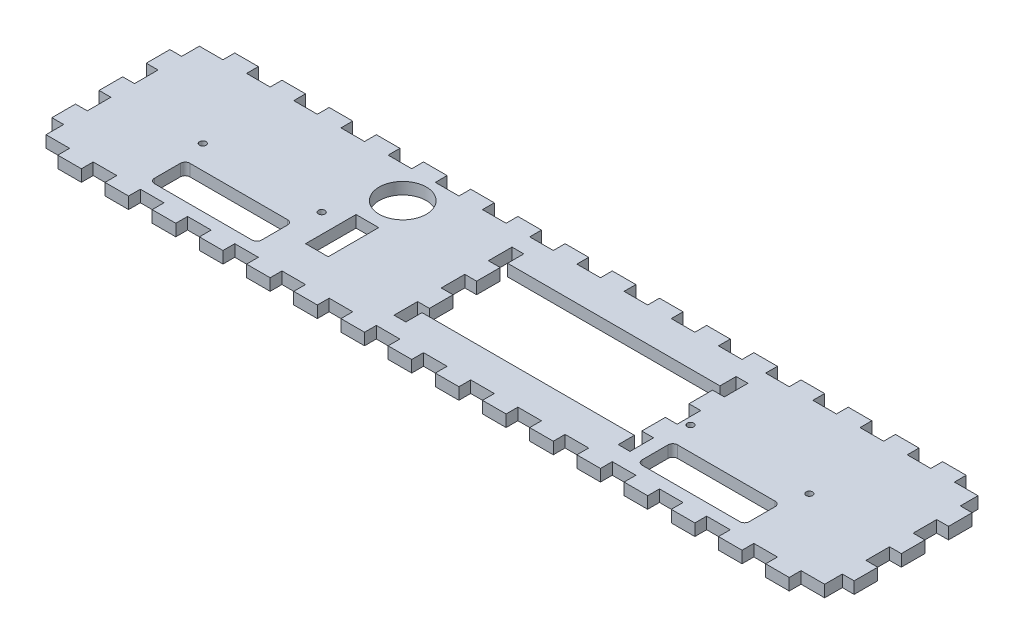
from build123d import *

# Parameters (mm, degrees)
SKETCH1_W           = 431.8
SKETCH1_H           = 95.25
BOSS_EXTRUDE1_DEPTH = 6.35
SKETCH2_W           = 12.7
SKETCH2_H           = 6.35
CUT_EXTRUDE1_DEPTH  = 7.35
LPATTERN1_COUNT     = 17
LPATTERN1_PITCH     = 25.4
SKETCH3_W           = 6.35
SKETCH3_H           = 6.35
CUT_EXTRUDE2_DEPTH  = 7.35
SKETCH5_W           = 6.35
SKETCH5_H           = 12.7
CUT_EXTRUDE4_DEPTH  = 7.35
LPATTERN2_COUNT     = 2
LPATTERN2_PITCH     = 25.4
LPATTERN2_COL_COUNT = 2
LPATTERN2_COL_PITCH = 25.4
SKETCH6_W           = 114.3
SKETCH6_H           = 46.0375
CUT_EXTRUDE5_DEPTH  = 7.35
SKETCH7_R           = 1.75
CUT_EXTRUDE6_DEPTH  = 7.35
SKETCH8_W           = 6.35
SKETCH8_H           = 9.525
SKETCH8_H_2         = 12.7
CUT_EXTRUDE7_DEPTH  = 7.35
LPATTERN3_COUNT     = 2
LPATTERN3_PITCH     = 425.45
SKETCH9_R           = 12.7
SKETCH9_W           = 12.192
SKETCH9_H           = 27.178
CUT_EXTRUDE8_DEPTH  = 7.35
SKETCH10_W          = 57.65
SKETCH10_H          = 19.05
CUT_EXTRUDE9_DEPTH  = 7.35
FILLET1_R           = 2.54


with BuildPart() as part:
    # Sketch1 → Boss-Extrude1 (new body)
    with BuildSketch(Plane(origin=(0, 0, 0), x_dir=(1, 0, 0), z_dir=(0, 1, 0))):
        with Locations((215.9, 47.625)):
            Rectangle(SKETCH1_W, SKETCH1_H)
    extrude(amount=BOSS_EXTRUDE1_DEPTH)

    # Sketch2 → Cut-Extrude1 (cut, through all)
    with BuildSketch(Plane(origin=(0, 6.35, 0), x_dir=(1, 0, 0), z_dir=(0, 1, 0))):
        with Locations((12.7, 92.075)):
            Rectangle(SKETCH2_W, SKETCH2_H)
        with Locations((12.7, 3.175)):
            Rectangle(SKETCH2_W, SKETCH2_H)
    cut_extrude1 = extrude(amount=-CUT_EXTRUDE1_DEPTH, mode=Mode.SUBTRACT)

    # LPattern1: Cut-Extrude1 ×17
    with Locations(*[(i * LPATTERN1_PITCH, 0, 0) for i in range(1, LPATTERN1_COUNT)]):
        add(cut_extrude1, mode=Mode.SUBTRACT)

    # Sketch3 → Cut-Extrude2 (cut, through all)
    with BuildSketch(Plane(origin=(0, 6.35, 0), x_dir=(1, 0, 0), z_dir=(0, 1, 0))):
        with Locations((3.175, 92.075)):
            Rectangle(SKETCH3_W, SKETCH3_H)
        with Locations((3.175, 3.175)):
            Rectangle(SKETCH3_W, SKETCH3_H)
        with Locations((428.625, 92.075)):
            Rectangle(SKETCH3_W, SKETCH3_H)
        with Locations((428.625, 3.175)):
            Rectangle(SKETCH3_W, SKETCH3_H)
    extrude(amount=-CUT_EXTRUDE2_DEPTH, mode=Mode.SUBTRACT)

    # Sketch5 → Cut-Extrude4 (cut, through all)
    with BuildSketch(Plane(origin=(0, 6.35, 0), x_dir=(1, 0, 0), z_dir=(0, 1, 0))):
        with Locations((187.325, 47.625)):
            Rectangle(SKETCH5_W, SKETCH5_H)
        with Locations((307.975, 47.625)):
            Rectangle(SKETCH5_W, SKETCH5_H)
    cut_extrude4 = extrude(amount=-CUT_EXTRUDE4_DEPTH, mode=Mode.SUBTRACT)

    # LPattern2: Cut-Extrude4 ×2
    with Locations(*[(0, 0, -i * LPATTERN2_PITCH) for i in range(1, LPATTERN2_COUNT)]):
        add(cut_extrude4, mode=Mode.SUBTRACT)

    # LPattern2 col: Cut-Extrude4 ×2
    with Locations(*[(0, 0, i * LPATTERN2_COL_PITCH) for i in range(1, LPATTERN2_COL_COUNT)]):
        add(cut_extrude4, mode=Mode.SUBTRACT)

    # Sketch6 → Cut-Extrude5 (cut, through all)
    with BuildSketch(Plane(origin=(0, 6.35, 0), x_dir=(1, 0, 0), z_dir=(0, 1, 0))):
        with Locations((247.65, 47.625)):
            Rectangle(SKETCH6_W, SKETCH6_H)
    extrude(amount=-CUT_EXTRUDE5_DEPTH, mode=Mode.SUBTRACT)

    # Sketch7 → Cut-Extrude6 (cut, through all)
    with BuildSketch(Plane(origin=(0, 6.35, 0), x_dir=(1, 0, 0), z_dir=(0, 1, 0))):
        with Locations((52.65, 44.45)):
            Circle(SKETCH7_R)
        with Locations((116.65, 44.45)):
            Circle(SKETCH7_R)
        with Locations((315.15, 44.45)):
            Circle(SKETCH7_R)
        with Locations((379.15, 44.45)):
            Circle(SKETCH7_R)
    extrude(amount=-CUT_EXTRUDE6_DEPTH, mode=Mode.SUBTRACT)

    # Sketch8 → Cut-Extrude7 (cut, through all)
    with BuildSketch(Plane(origin=(0, 6.35, 0), x_dir=(1, 0, 0), z_dir=(0, 1, 0))):
        with Locations((3.175, 84.1375)):
            Rectangle(SKETCH8_W, SKETCH8_H)
        with Locations((3.175, 11.1125)):
            Rectangle(SKETCH8_W, SKETCH8_H)
        with Locations((3.175, 34.925)):
            Rectangle(SKETCH8_W, SKETCH8_H_2)
        with Locations((3.175, 60.325)):
            Rectangle(SKETCH8_W, SKETCH8_H_2)
    cut_extrude7 = extrude(amount=-CUT_EXTRUDE7_DEPTH, mode=Mode.SUBTRACT)

    # LPattern3: Cut-Extrude7 ×2
    with Locations(*[(i * LPATTERN3_PITCH, 0, 0) for i in range(1, LPATTERN3_COUNT)]):
        add(cut_extrude7, mode=Mode.SUBTRACT)

    # Sketch9 → Cut-Extrude8 (cut, through all)
    with BuildSketch(Plane(origin=(0, 6.35, 0), x_dir=(1, 0, 0), z_dir=(0, 1, 0))):
        with Locations((133.096, 71.628)):
            Circle(SKETCH9_R)
        with Locations((133.096, 38.989)):
            Rectangle(SKETCH9_W, SKETCH9_H)
    extrude(amount=-CUT_EXTRUDE8_DEPTH, mode=Mode.SUBTRACT)

    # Sketch10 → Cut-Extrude9 (cut, through all)
    with BuildSketch(Plane(origin=(0, 6.35, 0), x_dir=(1, 0, 0), z_dir=(0, 1, 0))):
        with Locations((84.65, 22.225)):
            Rectangle(SKETCH10_W, SKETCH10_H)
        with Locations((347.15, 22.225)):
            Rectangle(SKETCH10_W, SKETCH10_H)
    extrude(amount=-CUT_EXTRUDE9_DEPTH, mode=Mode.SUBTRACT)

    # Fillet1
    fillet1_edges = [part.edges().sort_by_distance(p)[0] for p in [
        (55.825, 3.175, -12.7),
        (55.825, 3.175, -31.75),
        (113.475, 3.175, -31.75),
        (113.475, 3.175, -12.7),
        (318.325, 3.175, -12.7),
        (318.325, 3.175, -31.75),
        (375.975, 3.175, -31.75),
        (375.975, 3.175, -12.7),
    ]]
    fillet(fillet1_edges, radius=FILLET1_R)


solid = part.part
